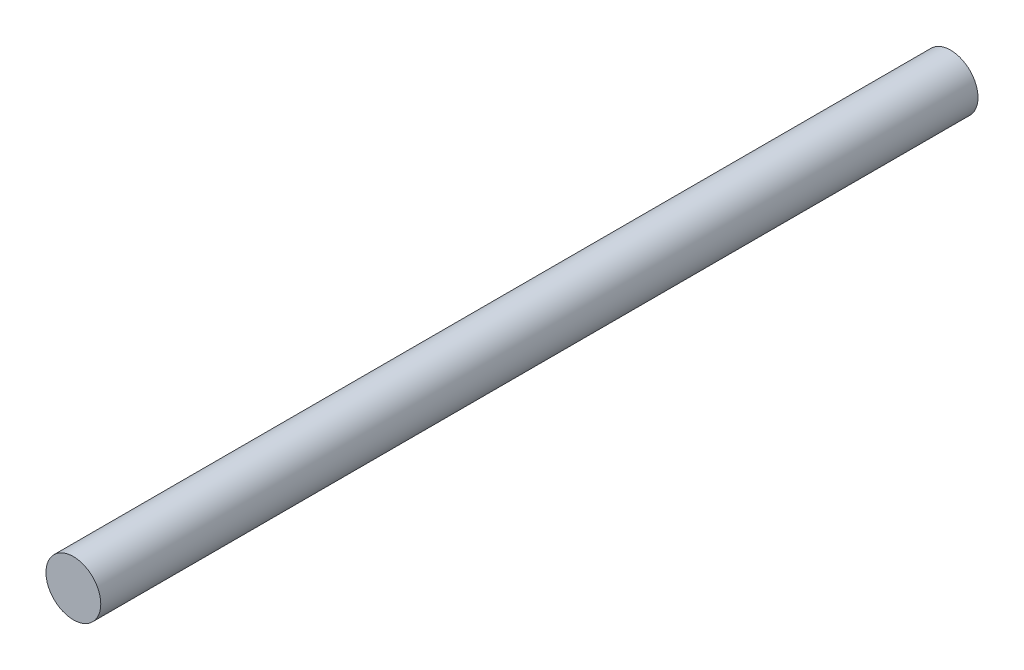
from build123d import *

# Parameters (mm, degrees)
SKETCH1_R           = 0.635
BOSS_EXTRUDE1_DEPTH = 20.32


with BuildPart() as part:
    # Sketch1 → Boss-Extrude1 (new body)
    with BuildSketch(Plane.XY):
        Circle(SKETCH1_R)
    extrude(amount=BOSS_EXTRUDE1_DEPTH)


solid = part.part
